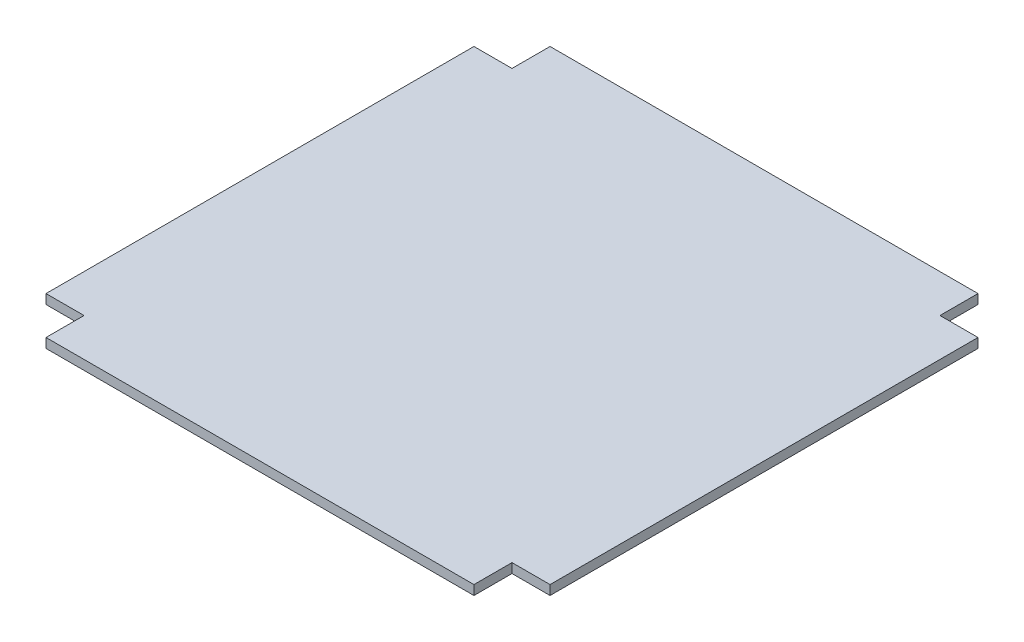
from build123d import *

# Parameters (mm, degrees)
SKETCH1_W           = 530
SKETCH1_H           = 530
BOSS_EXTRUDE1_DEPTH = 10
SKETCH2_W           = 40
SKETCH2_H           = 40
CUT_EXTRUDE1_DEPTH  = 11


with BuildPart() as part:
    # Sketch1 → Boss-Extrude1 (new body)
    with BuildSketch(Plane(origin=(0, 0, 0), x_dir=(1, 0, 0), z_dir=(0, 1, 0))):
        Rectangle(SKETCH1_W, SKETCH1_H)
    extrude(amount=BOSS_EXTRUDE1_DEPTH)

    # Sketch2 → Cut-Extrude1 (cut, through all)
    with BuildSketch(Plane(origin=(0, 10, 0), x_dir=(1, 0, 0), z_dir=(0, 1, 0))):
        with Locations((-245, 245)):
            Rectangle(SKETCH2_W, SKETCH2_H)
        with Locations((245, 245)):
            Rectangle(SKETCH2_W, SKETCH2_H)
        with Locations((-245, -245)):
            Rectangle(SKETCH2_W, SKETCH2_H)
        with Locations((245, -245)):
            Rectangle(SKETCH2_W, SKETCH2_H)
    extrude(amount=-CUT_EXTRUDE1_DEPTH, mode=Mode.SUBTRACT)


solid = part.part
